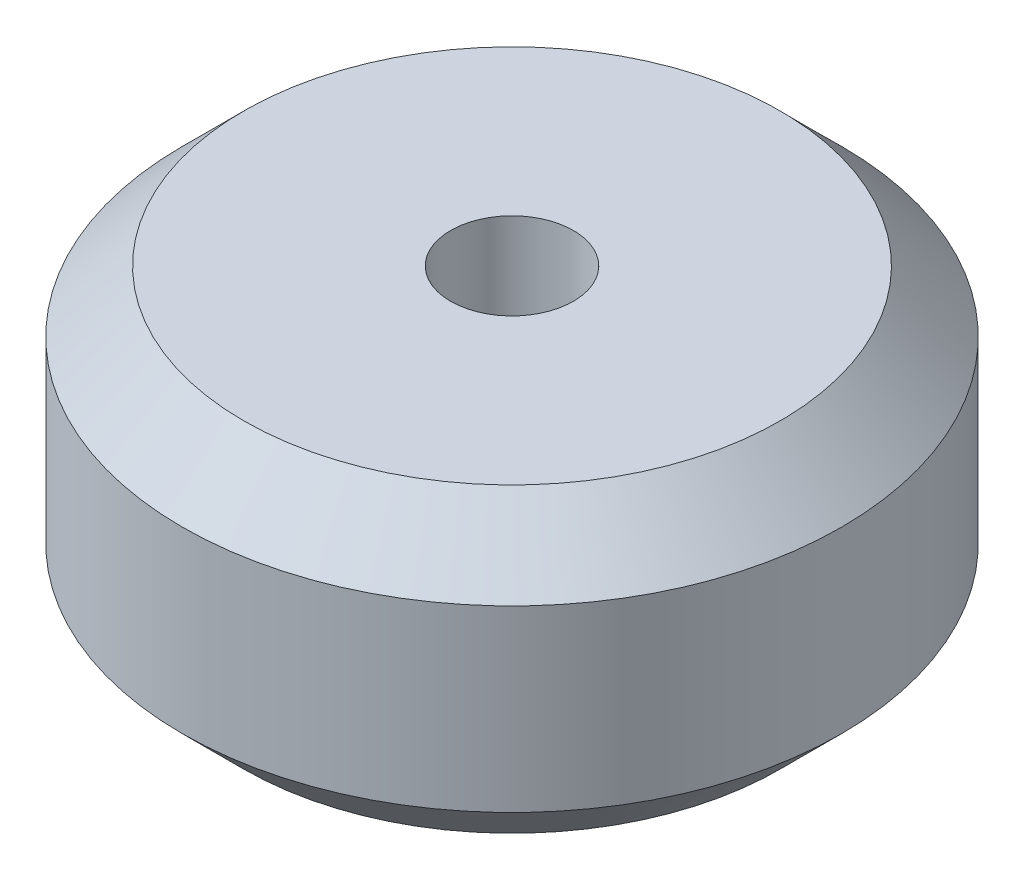
from build123d import *

# Parameters (mm, degrees)
SKETCH1_R           = 11.938
SKETCH1_R_2         = 2.2225
BOSS_EXTRUDE1_DEPTH = 10.922
CHAMFER1_SIZE       = 2.2225


with BuildPart() as part:
    # Sketch1 → Boss-Extrude1 (new body)
    with BuildSketch(Plane(origin=(0, 0, 0), x_dir=(1, 0, 0), z_dir=(0, 1, 0))):
        Circle(SKETCH1_R)
        Circle(SKETCH1_R_2, mode=Mode.SUBTRACT)
    extrude(amount=BOSS_EXTRUDE1_DEPTH)

    # Chamfer1
    chamfer1_edges = [part.edges().sort_by_distance(p)[0] for p in [
        (-11.938, 0, 0),
        (-11.938, 10.922, 0),
    ]]
    chamfer(chamfer1_edges, length=CHAMFER1_SIZE)


solid = part.part
